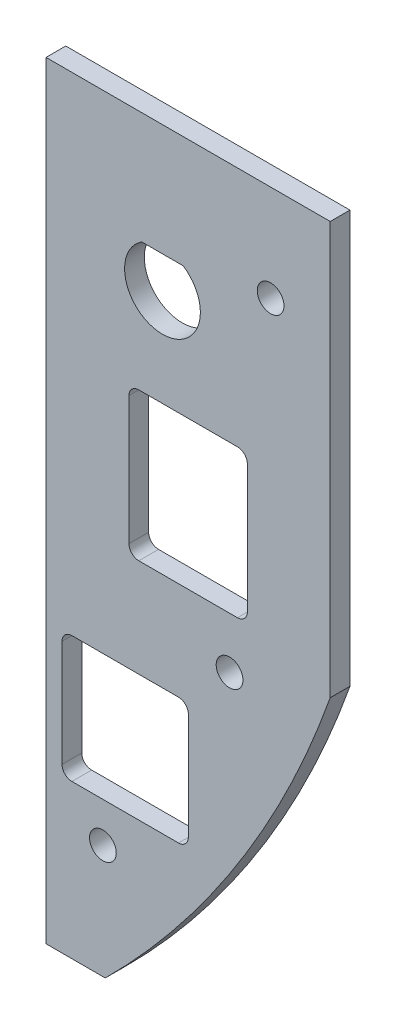
from build123d import *

# Parameters (mm, degrees)
SKETCH1_R             = 1.190050877
BOSS_EXTRUDE1_DEPTH   = 3.175
CUT_EXTRUDE1_DEPTH    = 4.175
SKETCH12_W            = 19.05
SKETCH12_H            = 23.8125
CUT_EXTRUDE2_DEPTH    = 4.175
SKETCH17_W            = 20.32
SKETCH17_H            = 20.32
CUT_EXTRUDE3_DEPTH    = 4.175
FILLET1_R             = 1.5875
F_6_CLEARANCE_HOLE1_D = 4.3053


with BuildPart() as part:
    # Sketch1 → Boss-Extrude1 (new body)
    with BuildSketch(Plane.XY):
        with BuildLine():
            Line((0, -17.78), (0, -141.2875))
            Line((0, -141.2875), (9.525, -141.2875))
            ThreePointArc((9.525, -141.2875), (30.833523511, -114.746148224), (45.72, -84.1375))
            Line((45.72, -84.1375), (45.72, -17.78))
            Line((45.72, -17.78), (0, -17.78))
        make_face()
        with Locations((18.7325, -40.894)):
            Circle(SKETCH1_R, mode=Mode.SUBTRACT)
    extrude(amount=-BOSS_EXTRUDE1_DEPTH)

    # Sketch11 → Cut-Extrude1 (cut, through all)
    with BuildSketch(Plane(origin=(20.844780046, -43.574770805, 0), x_dir=(1, 0, 0), z_dir=(0, 0, 1))):
        with BuildLine():
            Line((-5.443361979, 7.786170805), (1.218801886, 7.786170805))
            ThreePointArc((1.218801886, 7.786170805), (-2.112280046, -3.415229195), (-5.443361979, 7.786170805))
        make_face()
    extrude(amount=-CUT_EXTRUDE1_DEPTH, mode=Mode.SUBTRACT)

    # Sketch12 → Cut-Extrude2 (cut, through all)
    with BuildSketch(Plane.XY):
        with Locations((22.86, -68.54825)):
            Rectangle(SKETCH12_W, SKETCH12_H)
    extrude(amount=-CUT_EXTRUDE2_DEPTH, mode=Mode.SUBTRACT)

    # Sketch17 → Cut-Extrude3 (cut, through all)
    with BuildSketch(Plane.XY):
        with Locations((12.731722108, -106.422544949)):
            Rectangle(SKETCH17_W, SKETCH17_H)
    extrude(amount=-CUT_EXTRUDE3_DEPTH, mode=Mode.SUBTRACT)

    # Fillet1
    fillet1_edges = [part.edges().sort_by_distance(p)[0] for p in [
        (13.335, -80.4545, -1.5875),
        (13.335, -56.642, -1.5875),
        (32.385, -56.642, -1.5875),
        (32.385, -80.4545, -1.5875),
        (22.891722108, -96.262544949, -1.5875),
        (22.891722108, -116.582544949, -1.5875),
        (2.571722108, -116.582544949, -1.5875),
        (2.571722108, -96.262544949, -1.5875),
    ]]
    fillet(fillet1_edges, radius=FILLET1_R)

    # #6 Clearance Hole1 (through all)
    with Locations(Plane.XY):
        with Locations((9.144, -122.9995), (29.5275, -88.7095), (36.1315, -33.274)):
            Hole(F_6_CLEARANCE_HOLE1_D / 2)


solid = part.part
